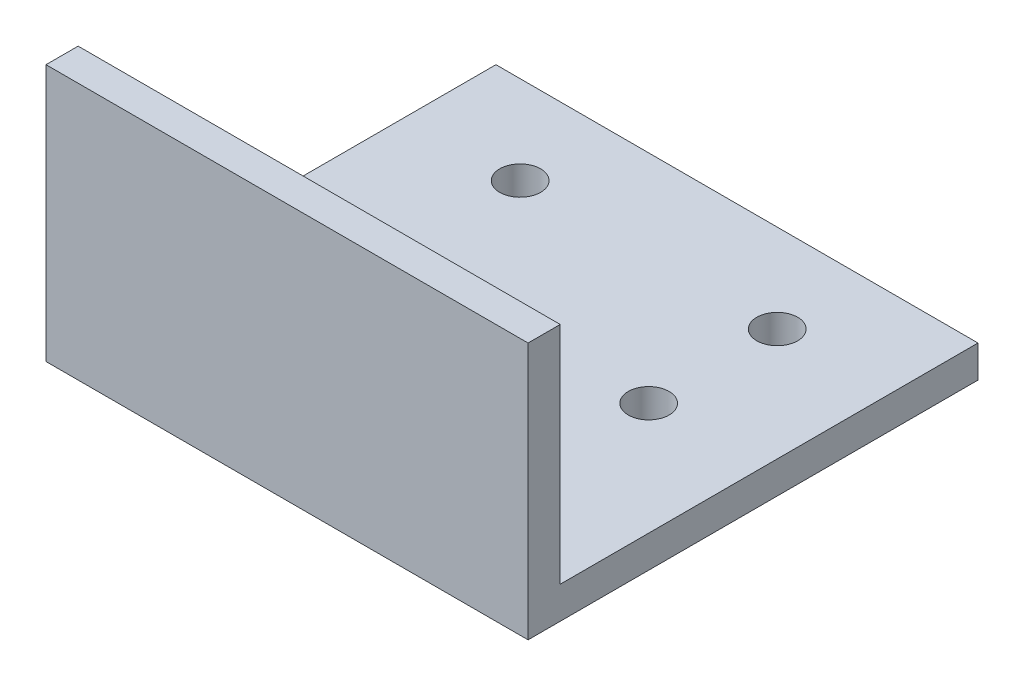
from build123d import *

# Parameters (mm, degrees)
BOSS_EXTRUDE1_DEPTH = 47.625
CUT_EXTRUDE1_REACH  = 5.175
SKETCH2_R           = 2.0193


with BuildPart() as part:
    # Sketch1 → Boss-Extrude1 (new body)
    with BuildSketch(Plane(origin=(0, 0, 0), x_dir=(0, 0, -1), z_dir=(1, 0, 0))):
        Polygon((3.175, 3.175), (3.175, 25.4), (0, 25.4), (0, 0), (44.45, 0), (44.45, 3.175), align=None)
    extrude(amount=BOSS_EXTRUDE1_DEPTH)

    # Sketch2 → Cut-Extrude1 (cut, up to next)
    with BuildSketch(Plane(origin=(0, 3.175, 0), x_dir=(1, 0, 0), z_dir=(0, 1, 0)), mode=Mode.PRIVATE) as cut_extrude1_sk1:
        with Locations((11.1125, 23.029)):
            Circle(SKETCH2_R)
    cut_extrude1_tool1 = extrude(cut_extrude1_sk1.sketch, amount=-CUT_EXTRUDE1_REACH, mode=Mode.PRIVATE) & part.part
    add(cut_extrude1_tool1.solids().sort_by_distance((11.1125, 3.175, -23.029))[0], mode=Mode.SUBTRACT)
    # Sketch2 → Cut-Extrude1 (cut, up to next)
    with BuildSketch(Plane(origin=(0, 3.175, 0), x_dir=(1, 0, 0), z_dir=(0, 1, 0)), mode=Mode.PRIVATE) as cut_extrude1_sk2:
        with Locations((11.1125, 35.729)):
            Circle(SKETCH2_R)
    cut_extrude1_tool2 = extrude(cut_extrude1_sk2.sketch, amount=-CUT_EXTRUDE1_REACH, mode=Mode.PRIVATE) & part.part
    add(cut_extrude1_tool2.solids().sort_by_distance((11.1125, 3.175, -35.729))[0], mode=Mode.SUBTRACT)
    # Sketch2 → Cut-Extrude1 (cut, up to next)
    with BuildSketch(Plane(origin=(0, 3.175, 0), x_dir=(1, 0, 0), z_dir=(0, 1, 0)), mode=Mode.PRIVATE) as cut_extrude1_sk3:
        with Locations((36.5125, 23.029)):
            Circle(SKETCH2_R)
    cut_extrude1_tool3 = extrude(cut_extrude1_sk3.sketch, amount=-CUT_EXTRUDE1_REACH, mode=Mode.PRIVATE) & part.part
    add(cut_extrude1_tool3.solids().sort_by_distance((36.5125, 3.175, -23.029))[0], mode=Mode.SUBTRACT)
    # Sketch2 → Cut-Extrude1 (cut, up to next)
    with BuildSketch(Plane(origin=(0, 3.175, 0), x_dir=(1, 0, 0), z_dir=(0, 1, 0)), mode=Mode.PRIVATE) as cut_extrude1_sk4:
        with Locations((36.5125, 35.729)):
            Circle(SKETCH2_R)
    cut_extrude1_tool4 = extrude(cut_extrude1_sk4.sketch, amount=-CUT_EXTRUDE1_REACH, mode=Mode.PRIVATE) & part.part
    add(cut_extrude1_tool4.solids().sort_by_distance((36.5125, 3.175, -35.729))[0], mode=Mode.SUBTRACT)


solid = part.part
